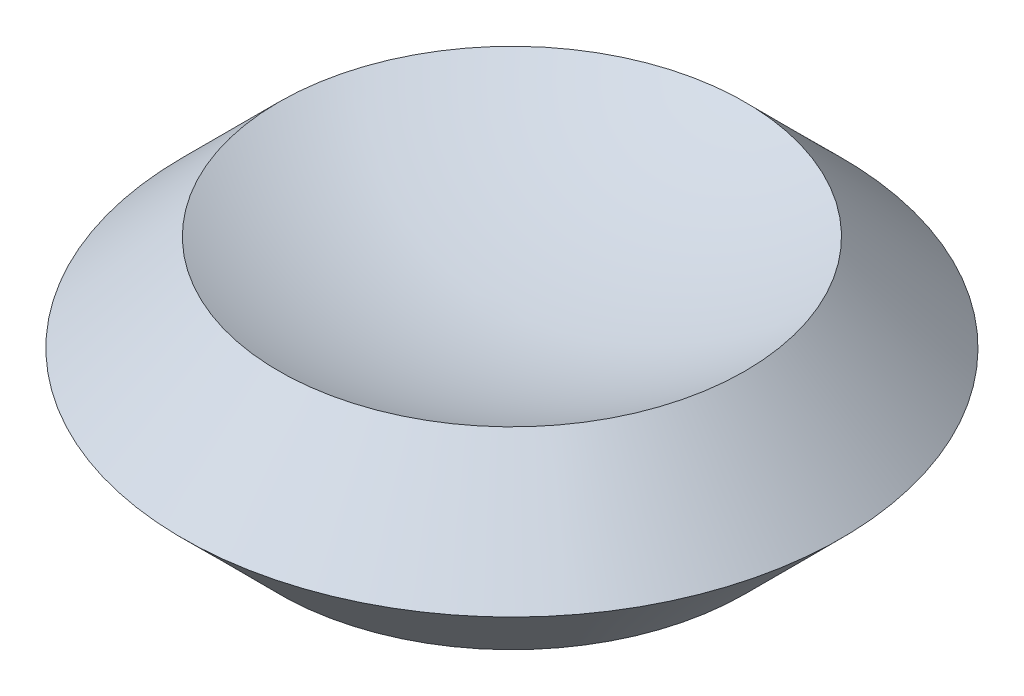
from build123d import *


with BuildPart() as part:
    # Electromagnetic Base Sketch → Electromagnetic Base Body (revolve)
    with BuildSketch(Plane.XY):
        with BuildLine():
            Line((0, 21.33), (0, 0))
            Line((0, 0), (-36.23, 0))
            Line((-36.23, 0), (-51.23, 15))
            Line((-51.23, 15), (-36.23, 30))
            ThreePointArc((-36.23, 30), (-18.626471754, 23.527673397), (0, 21.33))
        make_face()
    revolve(axis=Axis((0, 21.33, 0), (0, -1, 0)))


solid = part.part
